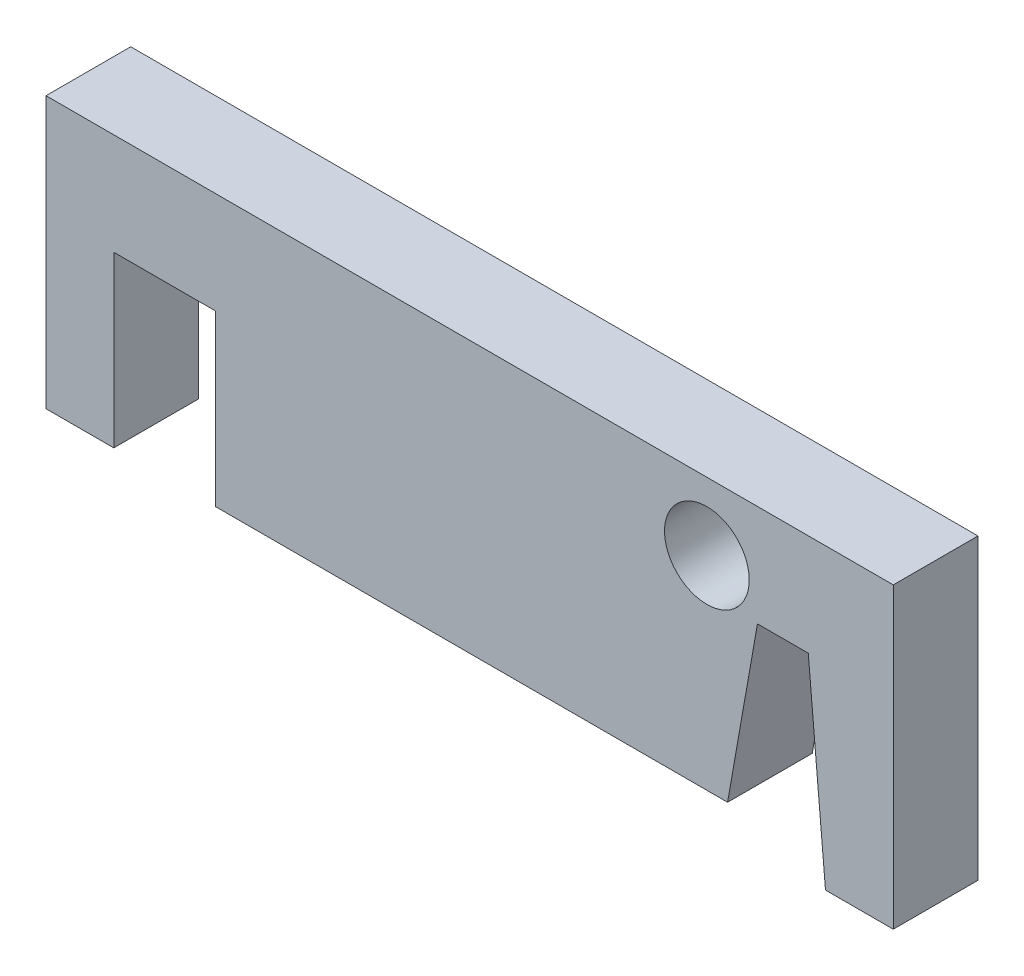
from build123d import *

# Parameters (mm, degrees)
SKETCH1_R           = 3.175
BOSS_EXTRUDE1_DEPTH = 3.175
SKETCH2_W           = 7.62
SKETCH2_H           = 12.7
CUT_EXTRUDE1_DEPTH  = 7.35


with BuildPart() as part:
    # Sketch1 → Boss-Extrude1 (new body, symmetric)
    with BuildSketch(Plane.XY):
        Polygon((21.571117009, -1.27), (25.381117009, -1.27), (25.82555942, -6.35), (31.75, -6.35), (31.75, 6.35), (0, 6.35), (-6.35, 6.35), (-31.75, 6.35), (-31.75, -6.35), (20.675375947, -6.35), align=None)
        with Locations((17.78, 1.27)):
            Circle(SKETCH1_R, mode=Mode.SUBTRACT)
        Polygon((19.331764354, -13.97), (20.675375947, -6.35), (-31.75, -6.35), (-31.75, -13.97), align=None)
        Polygon((31.75, -6.35), (25.82555942, -6.35), (26.67, -16.002), (31.75, -16.002), align=None)
    extrude(amount=BOSS_EXTRUDE1_DEPTH, both=True)

    # Sketch2 → Cut-Extrude1 (cut, through all)
    with BuildSketch(Plane.XY.offset(3.175)):
        with Locations((-22.86, -7.62)):
            Rectangle(SKETCH2_W, SKETCH2_H)
    extrude(amount=-CUT_EXTRUDE1_DEPTH, mode=Mode.SUBTRACT)


solid = part.part
